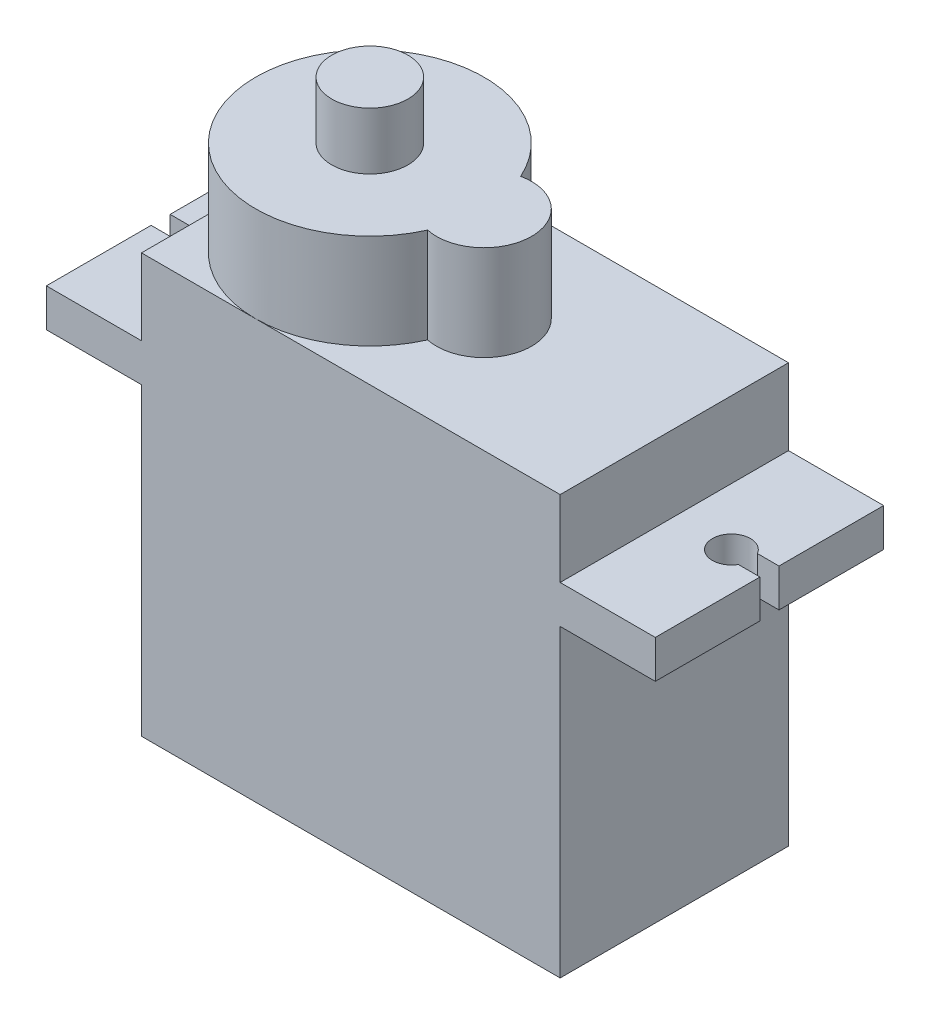
from build123d import *

# Parameters (mm, degrees)
SKETCH_1_W          = 22
SKETCH_1_H          = 12
EXTRUDE_1_DEPTH     = 22
EXTRUDE_2_DEPTH     = 5
SKETCH_4_R          = 2
EXTRUDE_3_DEPTH     = 3
SKETCH_5_W          = 5
SKETCH_5_H          = 2
EXTRUDE_4_DEPTH     = 12
SKETCH_6_W          = 3
SKETCH_6_H          = 1.5
EXTRUDE_5_DEPTH     = 3
CUT_EXTRUDE_1_DEPTH = 3


with BuildPart() as part:
    # 草图1 → 凸台-拉伸1 (new body)
    with BuildSketch(Plane(origin=(0, 0, 0), x_dir=(1, 0, 0), z_dir=(0, 1, 0))):
        Rectangle(SKETCH_1_W, SKETCH_1_H)
    extrude(amount=EXTRUDE_1_DEPTH)

    # 草图3 → 凸台-拉伸2 (add)
    with BuildSketch(Plane(origin=(0, 22, 0), x_dir=(1, 0, 0), z_dir=(0, 1, 0))):
        with BuildLine():
            ThreePointArc((0.479166667, 2.445144707), (-11, 0), (0.479166667, -2.445144707))
            ThreePointArc((0.479166667, -2.445144707), (3.5, 0), (0.479166667, 2.445144707))
        make_face()
    extrude(amount=EXTRUDE_2_DEPTH)

    # 草图4 → 凸台-拉伸3 (add)
    with BuildSketch(Plane(origin=(0, 27, 0), x_dir=(1, 0, 0), z_dir=(0, 1, 0))):
        with Locations((-5, 0)):
            Circle(SKETCH_4_R)
    extrude(amount=EXTRUDE_3_DEPTH)

    # 草图5 → 凸台-拉伸4 (add)
    with BuildSketch(Plane.XY.offset(6)):
        with Locations((-13.5, 17)):
            Rectangle(SKETCH_5_W, SKETCH_5_H)
        with Locations((13.5, 17)):
            Rectangle(SKETCH_5_W, SKETCH_5_H)
    extrude(amount=-EXTRUDE_4_DEPTH)

    # 草图6 → 凸台-拉伸5 (add)
    with BuildSketch(Plane.ZY.offset(11)):
        with Locations((0, 5.75)):
            Rectangle(SKETCH_6_W, SKETCH_6_H)
    extrude(amount=EXTRUDE_5_DEPTH)

    # 草图7 → 切除-拉伸1 (cut)
    with BuildSketch(Plane(origin=(0, 18, 0), x_dir=(1, 0, 0), z_dir=(0, 1, 0))):
        with BuildLine():
            Line((-16, -0.495646194), (-14.868524525, -0.495646194))
            ThreePointArc((-14.868524525, -0.495646194), (-13.000012637, -0.005027364), (-14.863497098, 0.504353806))
            Line((-14.863497098, 0.504353806), (-16, 0.504353806))
            Line((-16, 0.504353806), (-16, -0.495646194))
        make_face()
        with BuildLine():
            Line((14.866025404, -0.5), (16, -0.5))
            Line((16, -0.5), (16, 0.5))
            Line((16, 0.5), (14.866025404, 0.5))
            ThreePointArc((14.866025404, 0.5), (13, 0), (14.866025404, -0.5))
        make_face()
    extrude(amount=-CUT_EXTRUDE_1_DEPTH, mode=Mode.SUBTRACT)


solid = part.part
